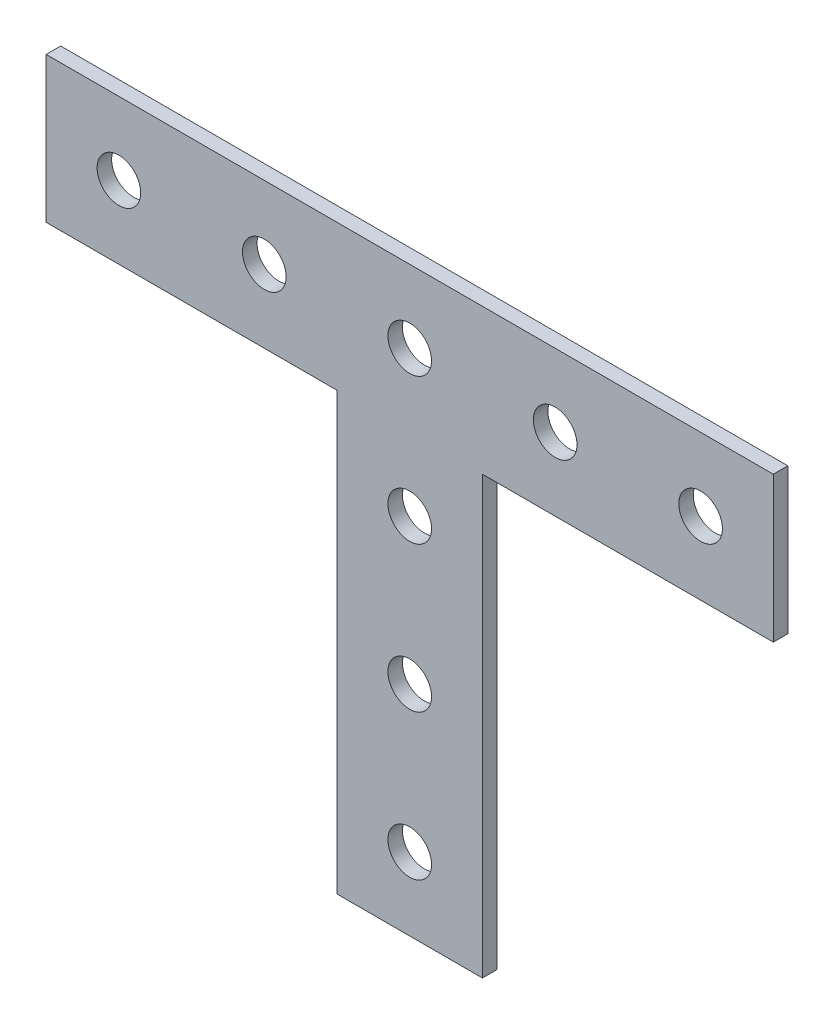
from build123d import *

# Parameters (mm, degrees)
BOSS_EXTRU_1_DEPTH         = 1
ESQUISSE2_R                = 1.5
ENL_V_MAT_EXTRU_1_DEPTH    = 2
R_P_TITION_LIN_AIRE1_COUNT = 3
R_P_TITION_LIN_AIRE1_PITCH = 10
R_P_TITION_LIN_AIRE2_COUNT = 3
R_P_TITION_LIN_AIRE2_PITCH = 10
R_P_TITION_LIN_AIRE3_COUNT = 4
R_P_TITION_LIN_AIRE3_PITCH = 10


with BuildPart() as part:
    # Esquisse1 → Boss.-Extru.1 (new body)
    with BuildSketch(Plane.XY):
        Polygon((-25, 10), (25, 10), (25, 0), (5, 0), (5, -30), (-5, -30), (-5, 0), (-25, 0), align=None)
    extrude(amount=BOSS_EXTRU_1_DEPTH)

    # Esquisse2 → Enlèv. mat.-Extru.1 (cut, through all)
    with BuildSketch(Plane.XY.offset(1)):
        with Locations((0, 5)):
            Circle(ESQUISSE2_R)
    enl_v_mat_extru_1 = extrude(amount=-ENL_V_MAT_EXTRU_1_DEPTH, mode=Mode.SUBTRACT)

    # Répétition linéaire1: Enlèv. mat.-Extru.1 ×3
    with Locations(*[(-i * R_P_TITION_LIN_AIRE1_PITCH, 0, 0) for i in range(1, R_P_TITION_LIN_AIRE1_COUNT)]):
        add(enl_v_mat_extru_1, mode=Mode.SUBTRACT)

    # Répétition linéaire2: Enlèv. mat.-Extru.1 ×3
    with Locations(*[(i * R_P_TITION_LIN_AIRE2_PITCH, 0, 0) for i in range(1, R_P_TITION_LIN_AIRE2_COUNT)]):
        add(enl_v_mat_extru_1, mode=Mode.SUBTRACT)

    # Répétition linéaire3: Enlèv. mat.-Extru.1 ×4
    with Locations(*[(0, -i * R_P_TITION_LIN_AIRE3_PITCH, 0) for i in range(1, R_P_TITION_LIN_AIRE3_COUNT)]):
        add(enl_v_mat_extru_1, mode=Mode.SUBTRACT)


solid = part.part
